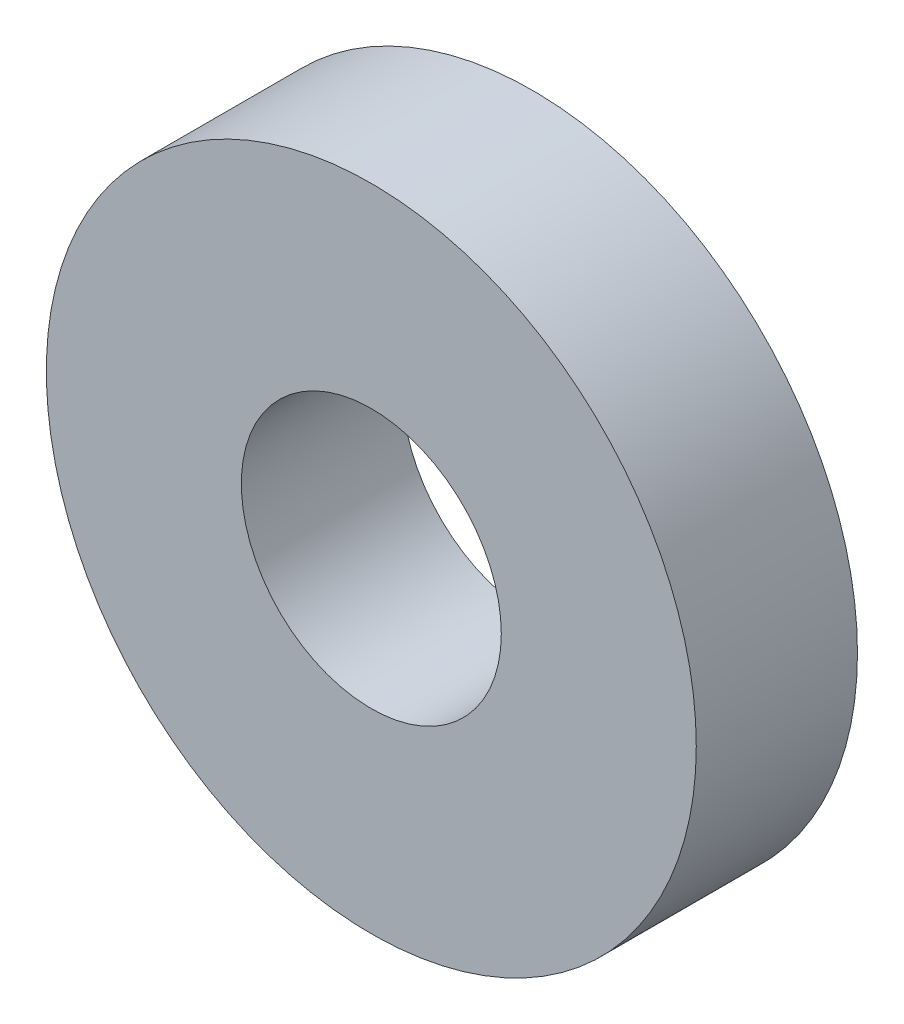
from build123d import *

# Parameters (mm, degrees)
SKETCH1_R           = 15.875
SKETCH1_R_2         = 6.35
BOSS_EXTRUDE1_DEPTH = 3.937


with BuildPart() as part:
    # Sketch1 → Boss-Extrude1 (new body, symmetric)
    with BuildSketch(Plane.XY):
        Circle(SKETCH1_R)
        Circle(SKETCH1_R_2, mode=Mode.SUBTRACT)
    extrude(amount=BOSS_EXTRUDE1_DEPTH, both=True)


solid = part.part
